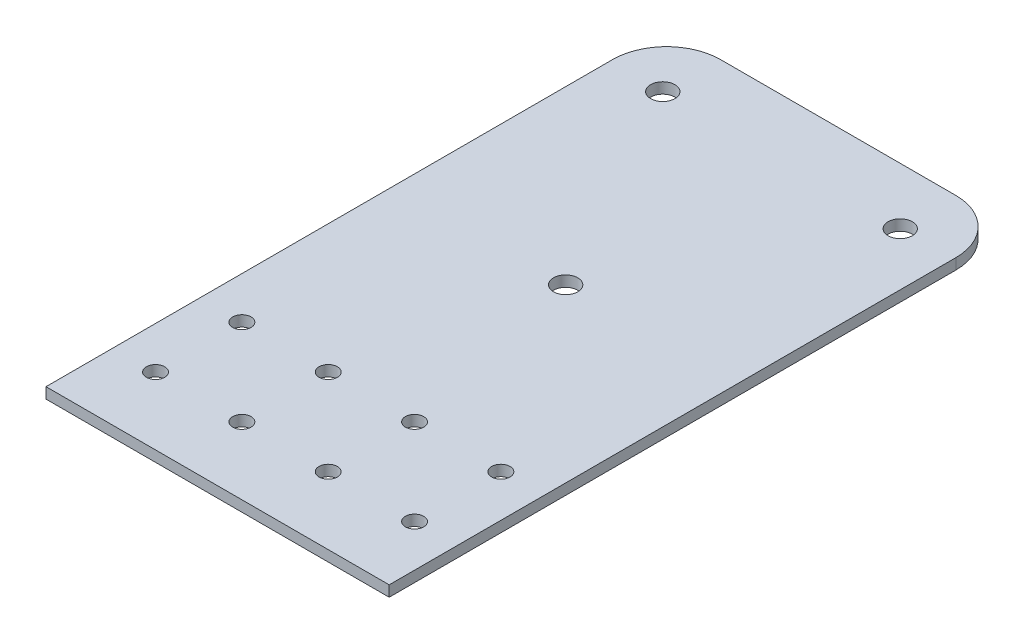
from build123d import *

# Parameters (mm, degrees)
SHEET_EXTRUDE_DEPTH      = 31.8
M3_CLEARANCE_HOLE1_D     = 3.4
M3_CLEARANCE_HOLE1_DEPTH = 8.5
M3_CLEARANCE_HOLE1_TIP   = 1.021463052
M4_CLEARANCE_HOLE1_D     = 4.5
M4_CLEARANCE_HOLE1_DEPTH = 7.5
M4_CLEARANCE_HOLE1_TIP   = 1.351936393
FILLET1_R                = 10


with BuildPart() as part:
    # Sketch2 → Sheet Extrude (new body, symmetric)
    with BuildSketch(Plane(origin=(0, 0, 0), x_dir=(0, 0, -1), z_dir=(1, 0, 0))):
        Polygon((0, 0), (0, 2), (-35, 2), (-55, 2), (-115, 2), (-115, 0), (-55, 0), (-35, 0), align=None)
    extrude(amount=SHEET_EXTRUDE_DEPTH, both=True)

    # M3 Clearance Hole1
    with Locations(Plane(origin=(0, 2, 0), x_dir=(1, 0, 0), z_dir=(0, 1, 0))):
        with Locations((-24, -102.5), (-24, -86.5), (-8, -86.5), (-8, -102.5), (24, -102.5), (8, -102.5), (8, -86.5), (24, -86.5)):
            Hole(M3_CLEARANCE_HOLE1_D / 2, depth=M3_CLEARANCE_HOLE1_DEPTH)
            with Locations((0, 0, -(M3_CLEARANCE_HOLE1_DEPTH + M3_CLEARANCE_HOLE1_TIP / 2))):  # 118° drill point
                Cone(0, M3_CLEARANCE_HOLE1_D / 2, M3_CLEARANCE_HOLE1_TIP, mode=Mode.SUBTRACT)

    # M4 Clearance Hole1
    with Locations(Plane(origin=(0, 2, 0), x_dir=(1, 0, 0), z_dir=(0, 1, 0))):
        with Locations((0, -50.5), (22, -10.5), (-22, -10.5)):
            Hole(M4_CLEARANCE_HOLE1_D / 2, depth=M4_CLEARANCE_HOLE1_DEPTH)
            with Locations((0, 0, -(M4_CLEARANCE_HOLE1_DEPTH + M4_CLEARANCE_HOLE1_TIP / 2))):  # 118° drill point
                Cone(0, M4_CLEARANCE_HOLE1_D / 2, M4_CLEARANCE_HOLE1_TIP, mode=Mode.SUBTRACT)

    # Fillet1
    fillet1_edges = [part.edges().sort_by_distance(p)[0] for p in [
        (-31.8, 1, 0),
        (31.8, 1, 0),
    ]]
    fillet(fillet1_edges, radius=FILLET1_R)


solid = part.part
